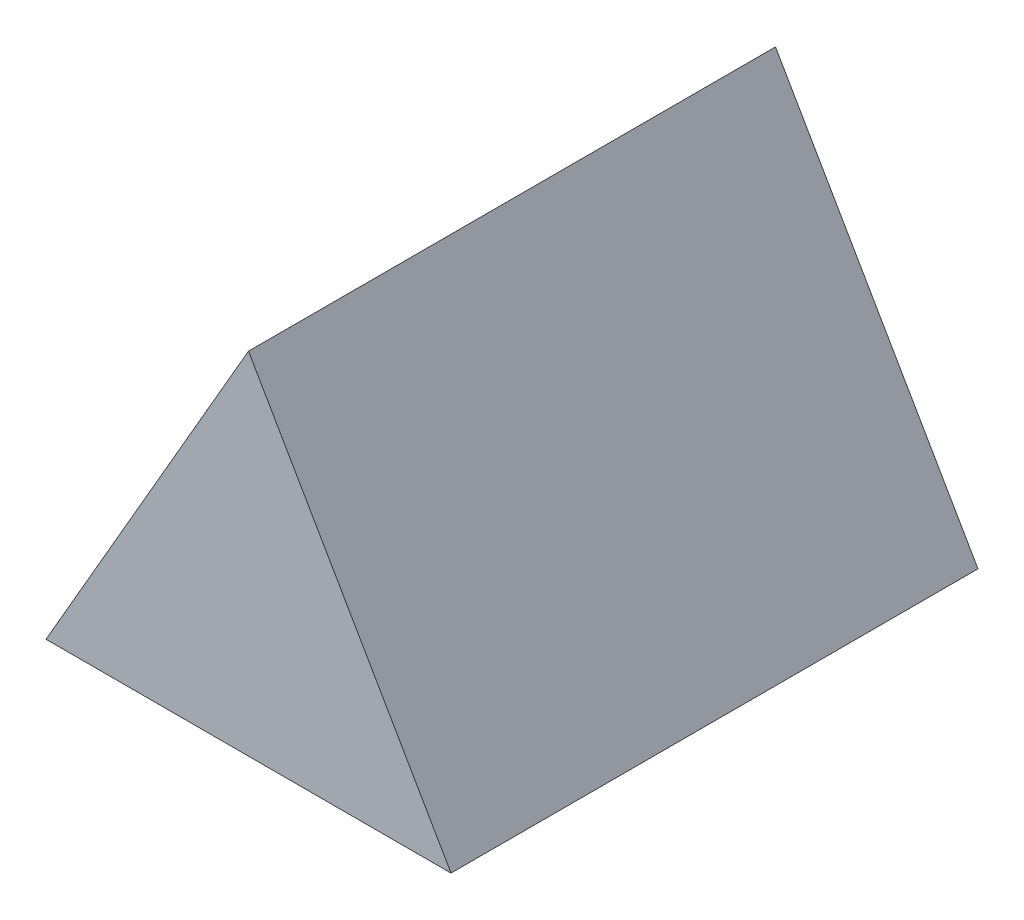
from build123d import *

# Parameters (mm, degrees)
ESTRUSIONE_ESTRUSIONE1_DEPTH = 160


with BuildPart() as part:
    # Schizzo1 → Estrusione-Estrusione1 (new body)
    with BuildSketch(Plane.XY):
        Polygon((0, 71), (-61.487803669, -35.5), (61.487803669, -35.5), align=None)
    extrude(amount=ESTRUSIONE_ESTRUSIONE1_DEPTH)


solid = part.part
